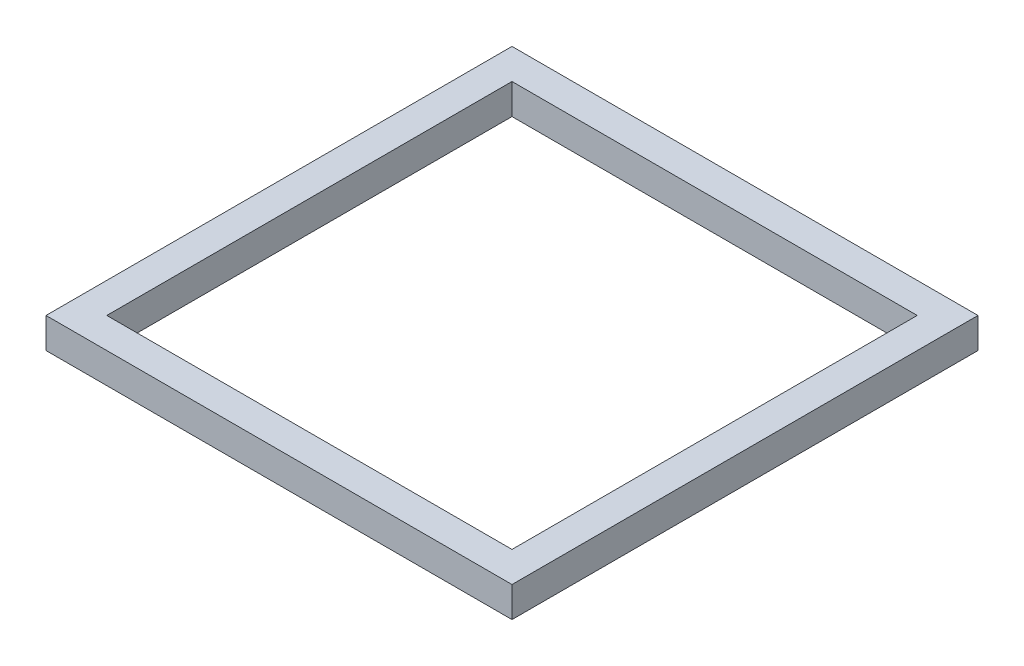
from build123d import *

# Parameters (mm, degrees)
CROQUIS1_W              = 46
CROQUIS1_H              = 46
CROQUIS1_W_2            = 40
CROQUIS1_H_2            = 40
SALIENTE_EXTRUIR1_DEPTH = 3


with BuildPart() as part:
    # Croquis1 → Saliente-Extruir1 (new body)
    with BuildSketch(Plane(origin=(0, 0, 0), x_dir=(1, 0, 0), z_dir=(0, 1, 0))):
        Rectangle(CROQUIS1_W, CROQUIS1_H)
        Rectangle(CROQUIS1_W_2, CROQUIS1_H_2, mode=Mode.SUBTRACT)
    extrude(amount=SALIENTE_EXTRUIR1_DEPTH)


solid = part.part
